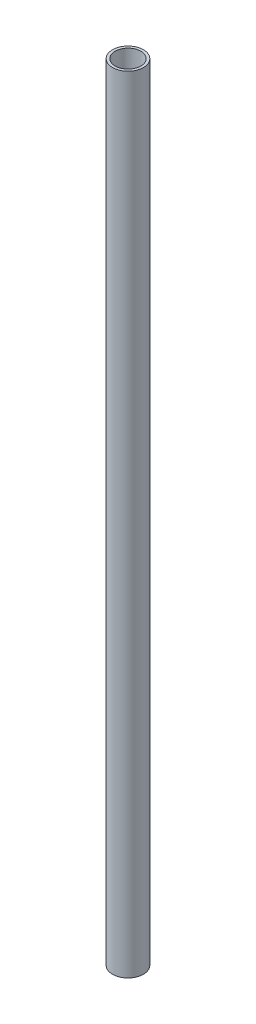
from build123d import *

# Parameters (mm, degrees)
SKETCH1_R           = 6
SKETCH1_R_2         = 5
BOSS_EXTRUDE1_DEPTH = 305


with BuildPart() as part:
    # Sketch1 → Boss-Extrude1 (new body)
    with BuildSketch(Plane(origin=(0, 0, 0), x_dir=(1, 0, 0), z_dir=(0, 1, 0))):
        Circle(SKETCH1_R)
        Circle(SKETCH1_R_2, mode=Mode.SUBTRACT)
    extrude(amount=BOSS_EXTRUDE1_DEPTH)


solid = part.part
